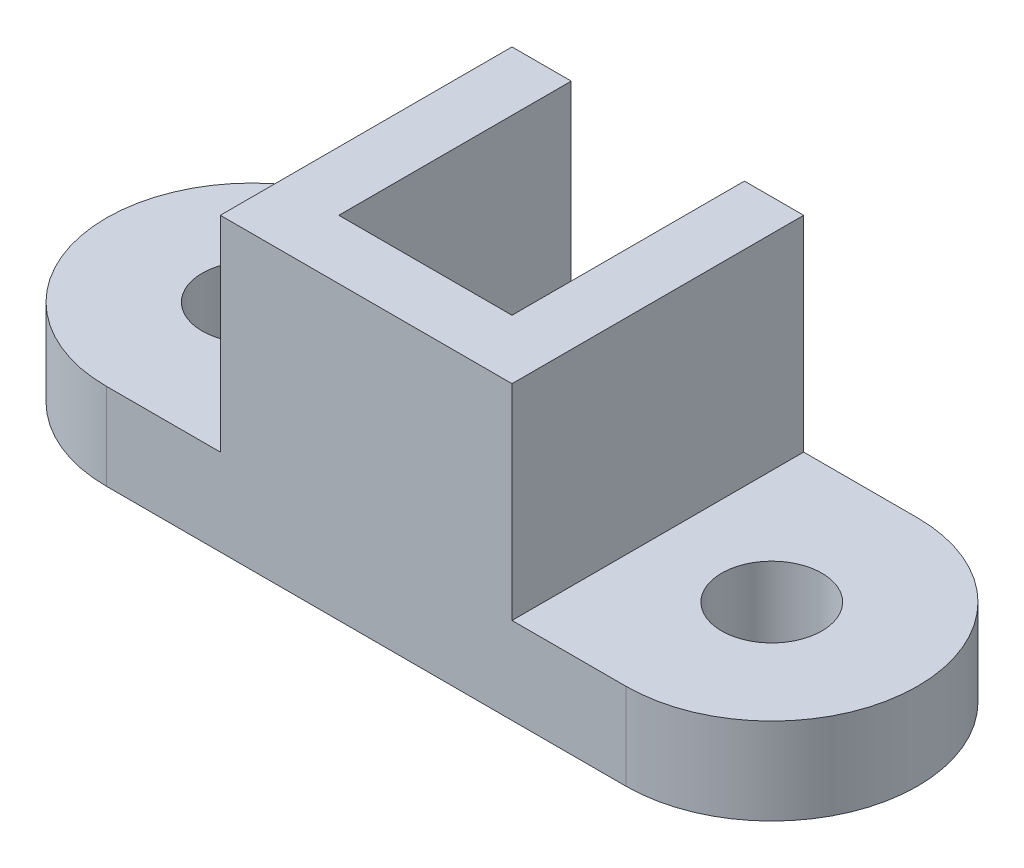
from build123d import *

# Parameters (mm, degrees)
SKETCH1_R           = 11
BOSS_EXTRUDE1_DEPTH = 19
SKETCH2_W           = 64
SKETCH2_H           = 64
BOSS_EXTRUDE2_DEPTH = 45
CUT_EXTRUDE4_DEPTH  = 19


with BuildPart() as part:
    # Sketch1 → Boss-Extrude1 (new body)
    with BuildSketch(Plane(origin=(0, 0, 0), x_dir=(1, 0, 0), z_dir=(0, 1, 0))):
        with BuildLine():
            Line((-57, 32), (57, 32))
            ThreePointArc((57, 32), (89, 0), (57, -32))
            Line((57, -32), (-57, -32))
            ThreePointArc((-57, -32), (-89, 0), (-57, 32))
        make_face()
        with Locations((-57, 0)):
            Circle(SKETCH1_R, mode=Mode.SUBTRACT)
        with Locations((57, 0)):
            Circle(SKETCH1_R, mode=Mode.SUBTRACT)
    extrude(amount=BOSS_EXTRUDE1_DEPTH)

    # Sketch2 → Boss-Extrude2 (add)
    with BuildSketch(Plane(origin=(0, 19, 0), x_dir=(1, 0, 0), z_dir=(0, 1, 0))):
        Rectangle(SKETCH2_W, SKETCH2_H)
    extrude(amount=BOSS_EXTRUDE2_DEPTH)

    # Sketch5 → Cut-Extrude4 (cut, symmetric)
    with BuildSketch(Plane(origin=(0, 0, 0), x_dir=(0, 0, -1), z_dir=(1, 0, 0))):
        Polygon((-19, 64), (32, 13), (32, 64), align=None)
    extrude(amount=CUT_EXTRUDE4_DEPTH, both=True, mode=Mode.SUBTRACT)


solid = part.part
